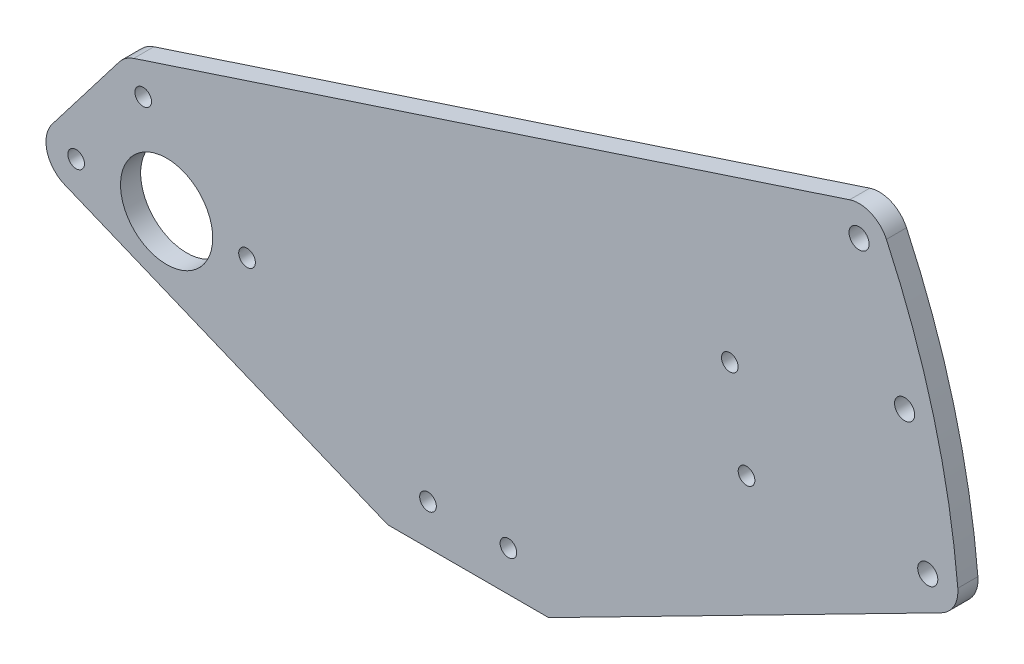
from build123d import *

# Parameters (mm, degrees)
SKETCH1_R           = 14.5542
SKETCH1_R_2         = 2.6289
SKETCH1_R_3         = 3.175
BOSS_EXTRUDE1_DEPTH = 6.35


with BuildPart() as part:
    # Sketch1 → Boss-Extrude1 (new body)
    with BuildSketch(Plane.XY):
        with BuildLine():
            Line((-36.131690566, 5.798452611), (-14.95244478, 33.399783098))
            ThreePointArc((-14.95244478, 33.399783098), (-12.907289703, 35.369766722), (-10.372281426, 36.649308755))
            Line((-10.372281426, 36.649308755), (215.715541799, 111.025764827))
            ThreePointArc((215.715541799, 111.025764827), (222.474160144, 110.71972065), (227.324650683, 106.003225501))
            ThreePointArc((227.324650683, 106.003225501), (242.278345379, 64.918286988), (249.870535149, 21.860839175))
            ThreePointArc((249.870535149, 21.860839175), (248.714513601, 16.416443349), (244.713320148, 12.547556856))
            Line((244.713320148, 12.547556856), (120.65, -50.8))
            Line((120.65, -50.8), (69.85, -50.8))
            Line((69.85, -50.8), (-32.199514598, -8.808434533))
            ThreePointArc((-32.199514598, -8.808434533), (-37.772560831, -2.475984603), (-36.131690566, 5.798452611))
        make_face()
        Circle(SKETCH1_R, mode=Mode.SUBTRACT)
        with Locations((-28.575, 0)):
            Circle(SKETCH1_R_2, mode=Mode.SUBTRACT)
        with Locations((-7.395754214, 27.601330486)):
            Circle(SKETCH1_R_2, mode=Mode.SUBTRACT)
        with Locations((240.38178065, 21.030680725)):
            Circle(SKETCH1_R_3, mode=Mode.SUBTRACT)
        with Locations((233.077901884, 62.453035583)):
            Circle(SKETCH1_R_3, mode=Mode.SUBTRACT)
        with Locations((218.692069012, 101.977786558)):
            Circle(SKETCH1_R_3, mode=Mode.SUBTRACT)
        with Locations((82.55, -38.1)):
            Circle(SKETCH1_R_2, mode=Mode.SUBTRACT)
        with Locations((107.95, -38.1)):
            Circle(SKETCH1_R_2, mode=Mode.SUBTRACT)
        with Locations((25.4, 0)):
            Circle(SKETCH1_R_2, mode=Mode.SUBTRACT)
        with Locations((177.875240911, 47.661527156)):
            Circle(SKETCH1_R_2, mode=Mode.SUBTRACT)
        with Locations((183.141207032, 19.248916511)):
            Circle(SKETCH1_R_2, mode=Mode.SUBTRACT)
    extrude(amount=BOSS_EXTRUDE1_DEPTH)


solid = part.part
